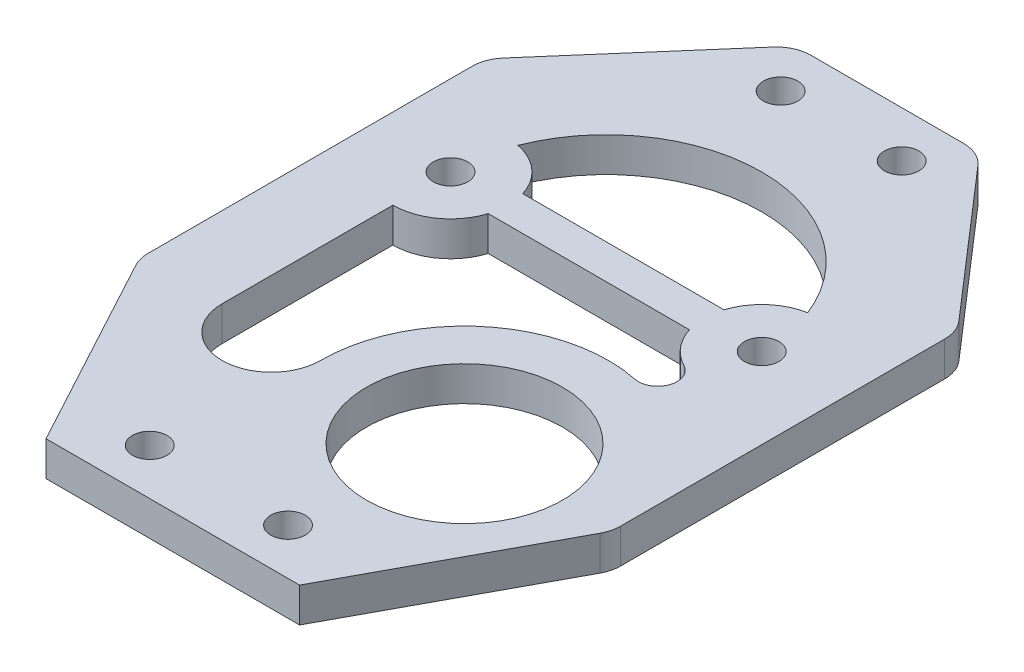
from build123d import *

# Parameters (mm, degrees)
CROQUIS1_R              = 8.5
CROQUIS1_R_2            = 1.5
SALIENTE_EXTRUIR1_DEPTH = 1.5
REDONDEO1_R             = 3


with BuildPart() as part:
    # Croquis1 → Saliente-Extruir1 (new body, symmetric)
    with BuildSketch(Plane(origin=(0, 0, 0), x_dir=(1, 0, 0), z_dir=(0, 1, 0))):
        Polygon((-11, 0), (11, 0), (20.5, 17.599715907), (20.5, 47.599715907), (8, 62), (-8, 62), (-20.5, 47.599715907), (-20.5, 17.599715907), align=None)
        with Locations((7.530163354, 17.782301135)):
            Circle(CROQUIS1_R, mode=Mode.SUBTRACT)
        with Locations((-5.25, 57.994261746)):
            Circle(CROQUIS1_R_2, mode=Mode.SUBTRACT)
        with Locations((-13.5, 37.599715907)):
            Circle(CROQUIS1_R_2, mode=Mode.SUBTRACT)
        with Locations((13.5, 37.599715907)):
            Circle(CROQUIS1_R_2, mode=Mode.SUBTRACT)
        with Locations((5.25, 57.994261746)):
            Circle(CROQUIS1_R_2, mode=Mode.SUBTRACT)
        with Locations((-6, 4)):
            Circle(CROQUIS1_R_2, mode=Mode.SUBTRACT)
        with Locations((6, 4)):
            Circle(CROQUIS1_R_2, mode=Mode.SUBTRACT)
        with BuildLine():
            Line((-8.730303993, 39.099715907), (8.730303993, 39.099715907))
            ThreePointArc((8.730303993, 39.099715907), (10.179901517, 41.338291312), (12.574074074, 42.513234115))
            ThreePointArc((12.574074074, 42.513234115), (0, 51.099715907), (-12.574074074, 42.513234115))
            ThreePointArc((-12.574074074, 42.513234115), (-10.179901517, 41.338291312), (-8.730303993, 39.099715907))
        make_face(mode=Mode.SUBTRACT)
        with BuildLine():
            Line((-13.5, 32.599715907), (-13.5, 17.782301135))
            ThreePointArc((-13.5, 17.782301135), (-9.234918323, 13.517219458), (-4.969836646, 17.782301135))
            ThreePointArc((-4.969836646, 17.782301135), (-0.361028795, 27.476582257), (10.06681719, 30.022210747))
            ThreePointArc((10.06681719, 30.022210747), (11.99598649, 31.106273213), (11.187975781, 33.166371344))
            ThreePointArc((11.187975781, 33.166371344), (9.667400631, 34.388612969), (8.730303993, 36.099715907))
            Line((8.730303993, 36.099715907), (-8.730303993, 36.099715907))
            ThreePointArc((-8.730303993, 36.099715907), (-10.541960108, 33.568587033), (-13.5, 32.599715907))
        make_face(mode=Mode.SUBTRACT)
    extrude(amount=SALIENTE_EXTRUIR1_DEPTH, both=True)

    # Redondeo1
    redondeo1_edges = [part.edges().sort_by_distance(p)[0] for p in [
        (-20.5, 0, -17.599715907),
        (-20.5, 0, -47.599715907),
        (-8, 0, -62),
        (8, 0, -62),
        (20.5, 0, -47.599715907),
        (20.5, 0, -17.599715907),
    ]]
    fillet(redondeo1_edges, radius=REDONDEO1_R)


solid = part.part
